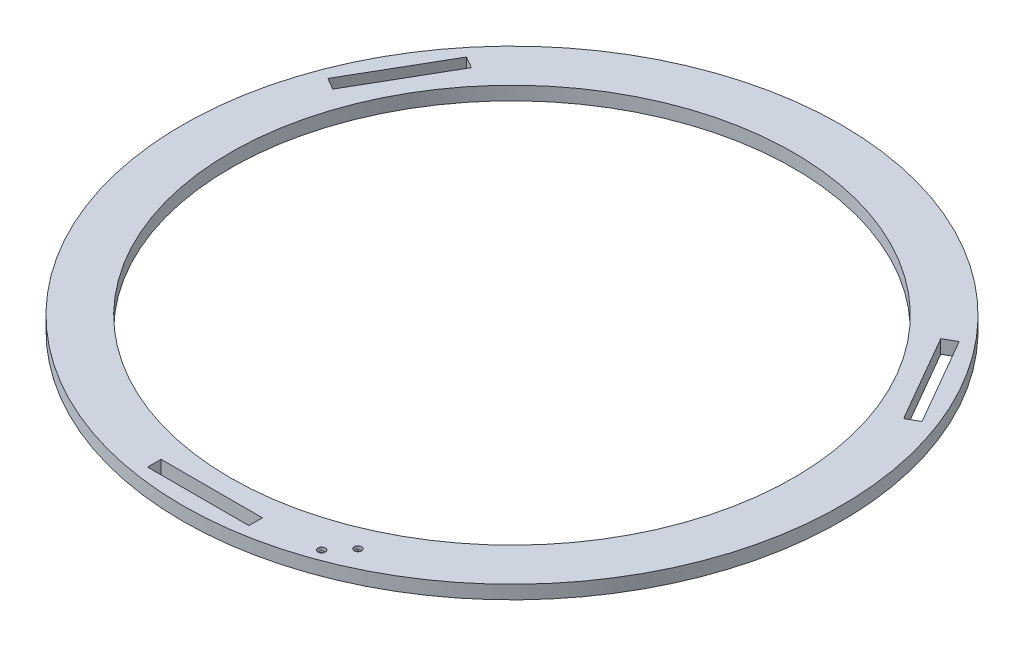
from build123d import *

# Parameters (mm, degrees)
SKETCH1_R                      = 292.5
SKETCH1_R_2                    = 250
BOSS_EXTRUDE1_DEPTH            = 12
SKETCH2_W                      = 90
SKETCH2_H                      = 12
CUT_EXTRUDE1_DEPTH             = 12
CIRPATTERN1_COUNT              = 3
CBORE_FOR_M3_SHCS1_D           = 3.4
CBORE_FOR_M3_SHCS1_CBORE_D     = 6.5
CBORE_FOR_M3_SHCS1_CBORE_DEPTH = 3


with BuildPart() as part:
    # Sketch1 → Boss-Extrude1 (new body)
    with BuildSketch(Plane(origin=(0, 0, 0), x_dir=(1, 0, 0), z_dir=(0, 1, 0))):
        Circle(SKETCH1_R)
        Circle(SKETCH1_R_2, mode=Mode.SUBTRACT)
    extrude(amount=BOSS_EXTRUDE1_DEPTH)

    # Sketch2 → Cut-Extrude1 (cut)
    with BuildSketch(Plane(origin=(0, 12, 0), x_dir=(1, 0, 0), z_dir=(0, 1, 0))):
        with Locations((0, -272.5)):
            Rectangle(SKETCH2_W, SKETCH2_H)
    cut_extrude1 = extrude(amount=-CUT_EXTRUDE1_DEPTH, mode=Mode.SUBTRACT)

    # CirPattern1: Cut-Extrude1 ×3 about axis
    cirpattern1_axis = Axis((0, 0, 0), (0, 1, 0))
    for i in range(1, CIRPATTERN1_COUNT):
        add(cut_extrude1.rotate(cirpattern1_axis, i * 360 / CIRPATTERN1_COUNT), mode=Mode.SUBTRACT)

    # CBORE for M3 SHCS1 (through all)
    with Locations(Plane(origin=(0, 12, 0), x_dir=(1, 0, 0), z_dir=(0, 1, 0))):
        with Locations((111.175516554, -247.940494387), (96.081953174, -265.03974421)):
            CounterBoreHole(CBORE_FOR_M3_SHCS1_D / 2, CBORE_FOR_M3_SHCS1_CBORE_D / 2, CBORE_FOR_M3_SHCS1_CBORE_DEPTH)


solid = part.part
